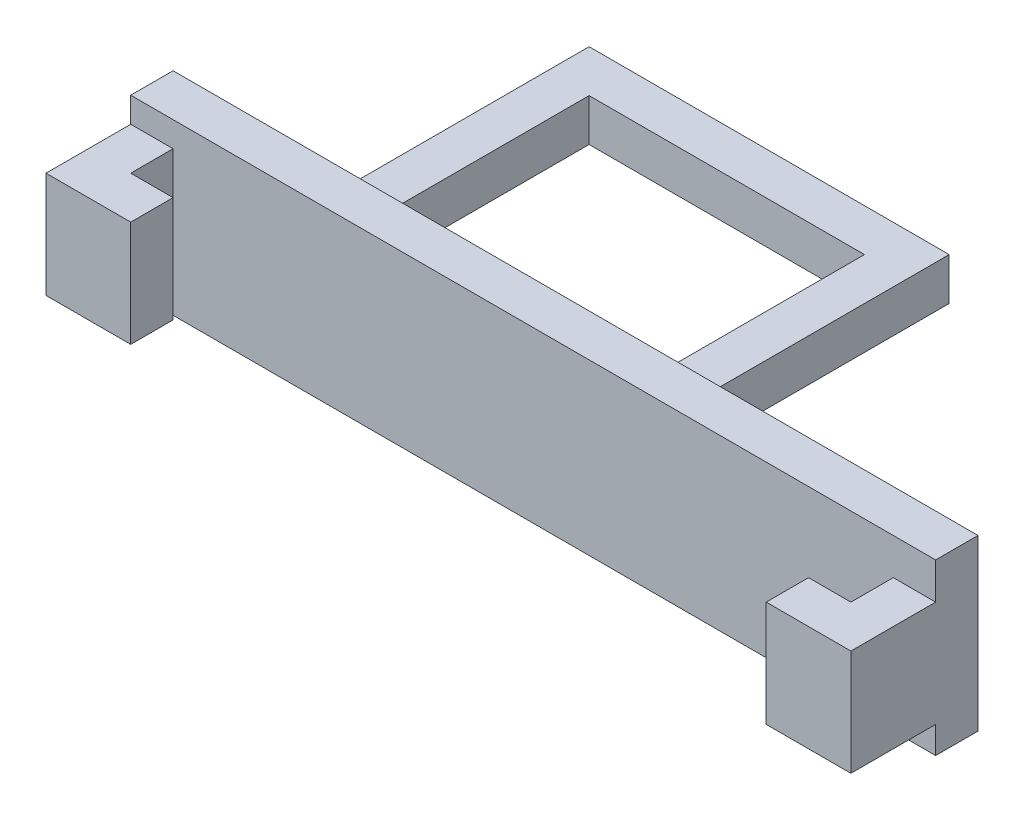
from build123d import *

# Parameters (mm, degrees)
SKETCH1_W           = 2
SKETCH1_H           = 2
BOSS_EXTRUDE1_DEPTH = 15
SKETCH4_W           = 2
SKETCH4_H           = 2
BOSS_EXTRUDE3_DEPTH = 15
SKETCH5_W           = 2
SKETCH5_H           = 2
BOSS_EXTRUDE4_DEPTH = 11
SKETCH6_W           = 38
SKETCH6_H           = 8
BOSS_EXTRUDE5_DEPTH = 2
SKETCH8_W           = 4
SKETCH8_H           = 5
BOSS_EXTRUDE6_DEPTH = 2
SKETCH9_W           = 4
SKETCH9_H           = 5
BOSS_EXTRUDE7_DEPTH = 2
SKETCH10_W          = 2
SKETCH10_H          = 5
BOSS_EXTRUDE8_DEPTH = 2
SKETCH11_W          = 2
SKETCH11_H          = 5
BOSS_EXTRUDE9_DEPTH = 2


with BuildPart() as part:
    # Sketch1 → Boss-Extrude1 (new body)
    with BuildSketch(Plane.XY):
        Rectangle(SKETCH1_W, SKETCH1_H)
    extrude(amount=BOSS_EXTRUDE1_DEPTH)

    # Sketch4 → Boss-Extrude3 (add)
    with BuildSketch(Plane(origin=(1, 0, 0), x_dir=(0, 0, -1), z_dir=(1, 0, 0))):
        with Locations((-1, 0)):
            Rectangle(SKETCH4_W, SKETCH4_H)
    extrude(amount=BOSS_EXTRUDE3_DEPTH)

    # Sketch5 → Boss-Extrude4 (add)
    with BuildSketch(Plane.XY.offset(2)):
        with Locations((15, 0)):
            Rectangle(SKETCH5_W, SKETCH5_H)
    extrude(amount=BOSS_EXTRUDE4_DEPTH)

    # Sketch6 → Boss-Extrude5 (add)
    with BuildSketch(Plane.XY.offset(15)):
        with Locations((13.360084104, 1.19652769)):
            Rectangle(SKETCH6_W, SKETCH6_H)
    extrude(amount=BOSS_EXTRUDE5_DEPTH)

    # Sketch8 → Boss-Extrude6 (add)
    with BuildSketch(Plane(origin=(32.360084104, 0, 0), x_dir=(0, 0, -1), z_dir=(1, 0, 0))):
        with Locations((-19, 0.971825631)):
            Rectangle(SKETCH8_W, SKETCH8_H)
    extrude(amount=-BOSS_EXTRUDE6_DEPTH)

    # Sketch9 → Boss-Extrude7 (add)
    with BuildSketch(Plane.ZY.offset(5.639915896)):
        with Locations((19, 1.508383794)):
            Rectangle(SKETCH9_W, SKETCH9_H)
    extrude(amount=-BOSS_EXTRUDE7_DEPTH)

    # Sketch10 → Boss-Extrude8 (add)
    with BuildSketch(Plane(origin=(-3.639915896, 0, 0), x_dir=(0, 0, -1), z_dir=(1, 0, 0))):
        with Locations((-20, 1.508383794)):
            Rectangle(SKETCH10_W, SKETCH10_H)
    extrude(amount=BOSS_EXTRUDE8_DEPTH)

    # Sketch11 → Boss-Extrude9 (add)
    with BuildSketch(Plane.ZY.offset(-30.360084104)):
        with Locations((20, 0.971825631)):
            Rectangle(SKETCH11_W, SKETCH11_H)
    extrude(amount=BOSS_EXTRUDE9_DEPTH)


solid = part.part
